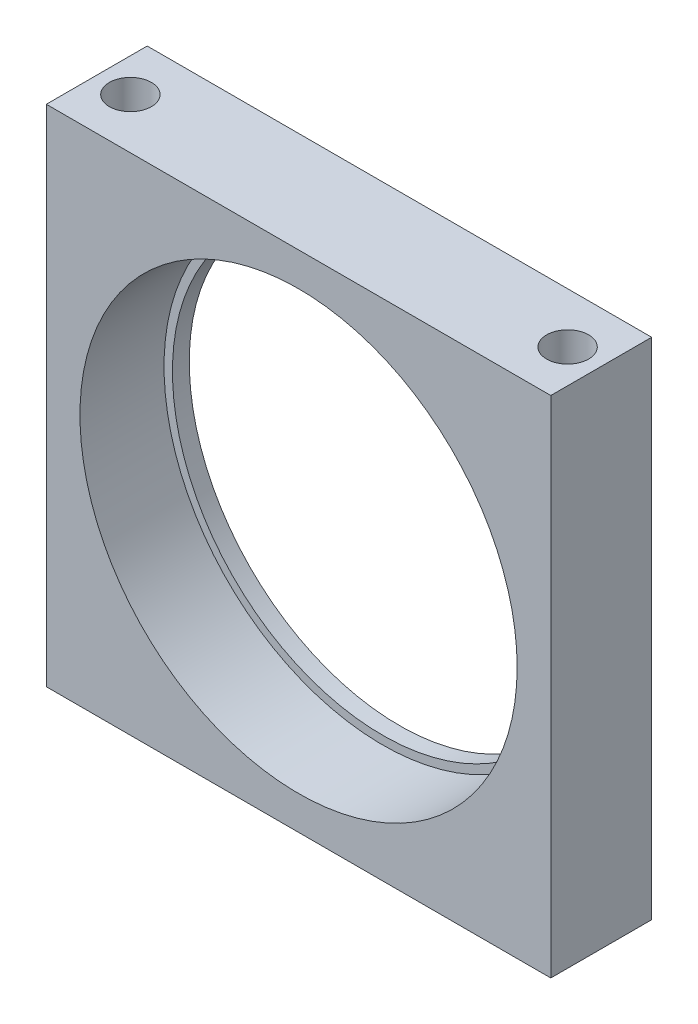
from build123d import *

# Parameters (mm, degrees)
ESQUISSE1_W                                   = 30
ESQUISSE1_H                                   = 30
ESQUISSE1_R                                   = 12.5
BOSS_EXTRU_1_DEPTH                            = 6
ESQUISSE3_R                                   = 13
ENL_V_MAT_EXTRU_1_DEPTH                       = 5
TROU_POUR_TARAUDAGE_POUR_TROU_TARAUD_M3_D     = 2.5
TROU_POUR_TARAUDAGE_POUR_TROU_TARAUD_M3_DEPTH = 6
TROU_POUR_TARAUDAGE_POUR_TROU_TARAUD_M3_TIP   = 0.751075774
TROU_POUR_TARAUDAGE_POUR_TROU_TARAUD_2_D      = 2.5
TROU_POUR_TARAUDAGE_POUR_TROU_TARAUD_2_DEPTH  = 6
TROU_POUR_TARAUDAGE_POUR_TROU_TARAUD_2_TIP    = 0.751075774


with BuildPart() as part:
    # Esquisse1 → Boss.-Extru.1 (new body)
    with BuildSketch(Plane.XY):
        with Locations((15, 15)):
            Rectangle(ESQUISSE1_W, ESQUISSE1_H)
        with Locations((15, 15)):
            Circle(ESQUISSE1_R, mode=Mode.SUBTRACT)
    extrude(amount=BOSS_EXTRU_1_DEPTH)

    # Esquisse3 → Enlèv. mat.-Extru.1 (cut)
    with BuildSketch(Plane.XY.offset(6)):
        with Locations((15, 15)):
            Circle(ESQUISSE3_R)
    extrude(amount=-ENL_V_MAT_EXTRU_1_DEPTH, mode=Mode.SUBTRACT)

    # Trou pour taraudage pour trou taraud_ M3
    with Locations(Plane(origin=(0, 30, 0), x_dir=(1, 0, 0), z_dir=(0, 1, 0))):
        with Locations((2, -3), (28, -3)):
            Hole(TROU_POUR_TARAUDAGE_POUR_TROU_TARAUD_M3_D / 2, depth=TROU_POUR_TARAUDAGE_POUR_TROU_TARAUD_M3_DEPTH)
            with Locations((0, 0, -(TROU_POUR_TARAUDAGE_POUR_TROU_TARAUD_M3_DEPTH + TROU_POUR_TARAUDAGE_POUR_TROU_TARAUD_M3_TIP / 2))):  # 118° drill point
                Cone(0, TROU_POUR_TARAUDAGE_POUR_TROU_TARAUD_M3_D / 2, TROU_POUR_TARAUDAGE_POUR_TROU_TARAUD_M3_TIP, mode=Mode.SUBTRACT)

    # Trou pour taraudage pour trou taraud 2
    with Locations(Plane(origin=(0, 0, 0), x_dir=(-1, 0, 0), z_dir=(0, -1, 0))):
        with Locations((-2, -3), (-28, -3)):
            Hole(TROU_POUR_TARAUDAGE_POUR_TROU_TARAUD_2_D / 2, depth=TROU_POUR_TARAUDAGE_POUR_TROU_TARAUD_2_DEPTH)
            with Locations((0, 0, -(TROU_POUR_TARAUDAGE_POUR_TROU_TARAUD_2_DEPTH + TROU_POUR_TARAUDAGE_POUR_TROU_TARAUD_2_TIP / 2))):  # 118° drill point
                Cone(0, TROU_POUR_TARAUDAGE_POUR_TROU_TARAUD_2_D / 2, TROU_POUR_TARAUDAGE_POUR_TROU_TARAUD_2_TIP, mode=Mode.SUBTRACT)


solid = part.part
